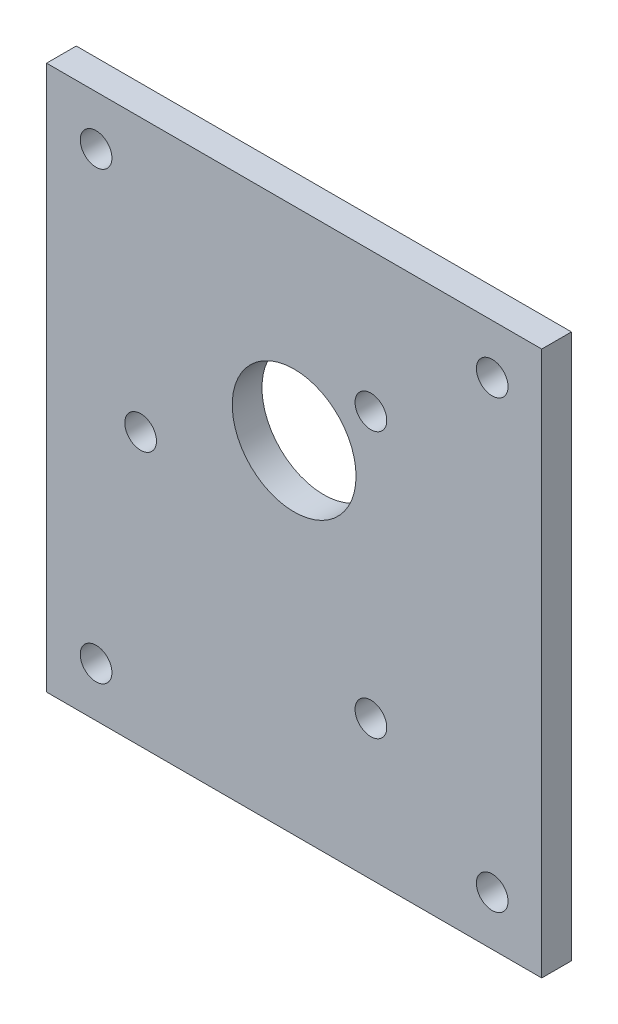
from build123d import *

# Parameters (mm, degrees)
SKETCH_1_W      = 50
SKETCH_1_H      = 55
SKETCH_1_R      = 6.25
SKETCH_1_R_2    = 1.6
EXTRUDE_1_DEPTH = 3


with BuildPart() as part:
    # ｽｹｯﾁ1 → ﾎﾞｽ - 押し出し1 (new body)
    with BuildSketch(Plane.XY):
        Rectangle(SKETCH_1_W, SKETCH_1_H)
        with Locations((0, 7)):
            Circle(SKETCH_1_R, mode=Mode.SUBTRACT)
        with Locations((-15.5, 0)):
            Circle(SKETCH_1_R_2, mode=Mode.SUBTRACT)
        with Locations((7.75, 13.423393759)):
            Circle(SKETCH_1_R_2, mode=Mode.SUBTRACT)
        with Locations((7.75, -13.423393759)):
            Circle(SKETCH_1_R_2, mode=Mode.SUBTRACT)
        with Locations((-20, 22.5)):
            Circle(SKETCH_1_R_2, mode=Mode.SUBTRACT)
        with Locations((20, 22.5)):
            Circle(SKETCH_1_R_2, mode=Mode.SUBTRACT)
        with Locations((-20, -22.5)):
            Circle(SKETCH_1_R_2, mode=Mode.SUBTRACT)
        with Locations((20, -22.5)):
            Circle(SKETCH_1_R_2, mode=Mode.SUBTRACT)
    extrude(amount=EXTRUDE_1_DEPTH)


solid = part.part
